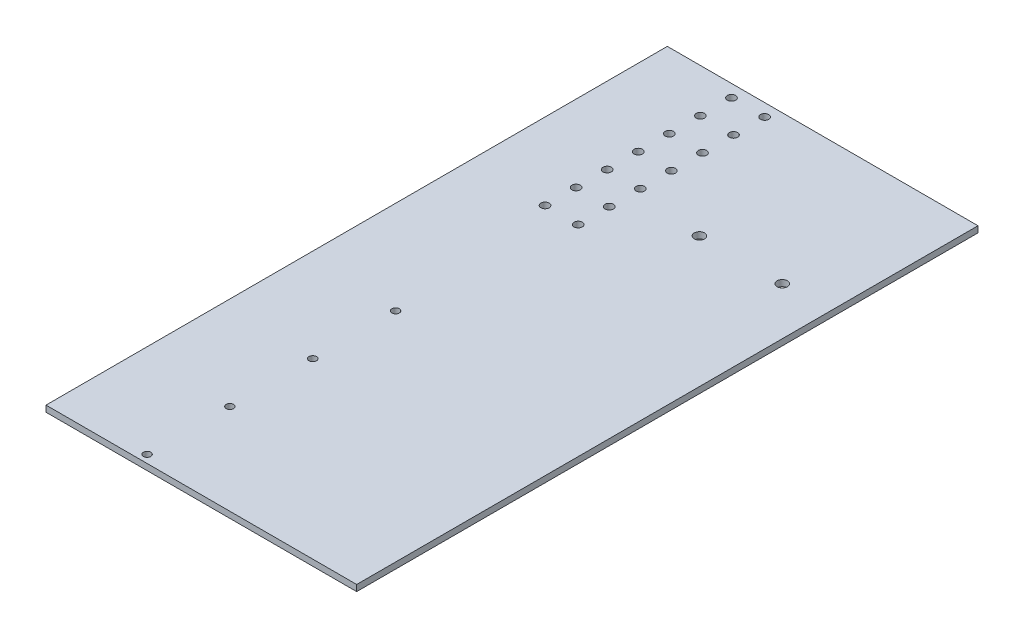
from build123d import *

# Parameters (mm, degrees)
SKETCH1_W           = 150
SKETCH1_H           = 300
BOSS_EXTRUDE1_DEPTH = 3
SKETCH2_R           = 2.5
CUT_EXTRUDE1_DEPTH  = 10
SKETCH3_R           = 1.8
CUT_EXTRUDE2_DEPTH  = 10
SKETCH4_R           = 2
CUT_EXTRUDE3_DEPTH  = 8.5
SKETCH5_R           = 2
CUT_EXTRUDE4_DEPTH  = 10


with BuildPart() as part:
    # Sketch1 → Boss-Extrude1 (new body)
    with BuildSketch(Plane(origin=(0, 0, 0), x_dir=(1, 0, 0), z_dir=(0, 1, 0))):
        Rectangle(SKETCH1_W, SKETCH1_H)
    extrude(amount=BOSS_EXTRUDE1_DEPTH)

    # Sketch2 → Cut-Extrude1 (cut)
    with BuildSketch(Plane.XZ):
        with Locations((52, -78.5)):
            Circle(SKETCH2_R)
        with Locations((12, -78.5)):
            Circle(SKETCH2_R)
    extrude(amount=-CUT_EXTRUDE1_DEPTH, mode=Mode.SUBTRACT)

    # Sketch3 → Cut-Extrude2 (cut)
    with BuildSketch(Plane(origin=(0, 3, 0), x_dir=(1, 0, 0), z_dir=(0, 1, 0))):
        with Locations((-30.006048092, -146.2)):
            Circle(SKETCH3_R)
        with Locations((-30.006048092, -106.2)):
            Circle(SKETCH3_R)
        with Locations((-30.006048092, -66.2)):
            Circle(SKETCH3_R)
        with Locations((-30.006048092, -26.2)):
            Circle(SKETCH3_R)
    extrude(amount=-CUT_EXTRUDE2_DEPTH, mode=Mode.SUBTRACT)

    # Sketch4 → Cut-Extrude3 (cut)
    with BuildSketch(Plane(origin=(0, 3, 0), x_dir=(1, 0, 0), z_dir=(0, 1, 0))):
        with Locations((-38.006048092, 53.968085801)):
            Circle(SKETCH4_R)
        with Locations((-22.006048092, 53.968085801)):
            Circle(SKETCH4_R)
    extrude(amount=-CUT_EXTRUDE3_DEPTH, mode=Mode.SUBTRACT)

    # Sketch5 → Cut-Extrude4 (cut)
    with BuildSketch(Plane(origin=(0, 3, 0), x_dir=(1, 0, 0), z_dir=(0, 1, 0))):
        with Locations((-38.006048092, 68.968085801)):
            Circle(SKETCH5_R)
        with Locations((-22.006048092, 68.968085801)):
            Circle(SKETCH5_R)
        with Locations((-38.006048092, 83.968085801)):
            Circle(SKETCH5_R)
        with Locations((-22.006048092, 83.968085801)):
            Circle(SKETCH5_R)
        with Locations((-38.006048092, 98.968085801)):
            Circle(SKETCH5_R)
        with Locations((-22.006048092, 98.968085801)):
            Circle(SKETCH5_R)
        with Locations((-38.006048092, 113.968085801)):
            Circle(SKETCH5_R)
        with Locations((-22.006048092, 113.968085801)):
            Circle(SKETCH5_R)
        with Locations((-38.006048092, 128.968085801)):
            Circle(SKETCH5_R)
        with Locations((-22.006048092, 128.968085801)):
            Circle(SKETCH5_R)
        with Locations((-38.006048092, 143.968085801)):
            Circle(SKETCH5_R)
        with Locations((-22.006048092, 143.968085801)):
            Circle(SKETCH5_R)
    extrude(amount=-CUT_EXTRUDE4_DEPTH, mode=Mode.SUBTRACT)


solid = part.part
